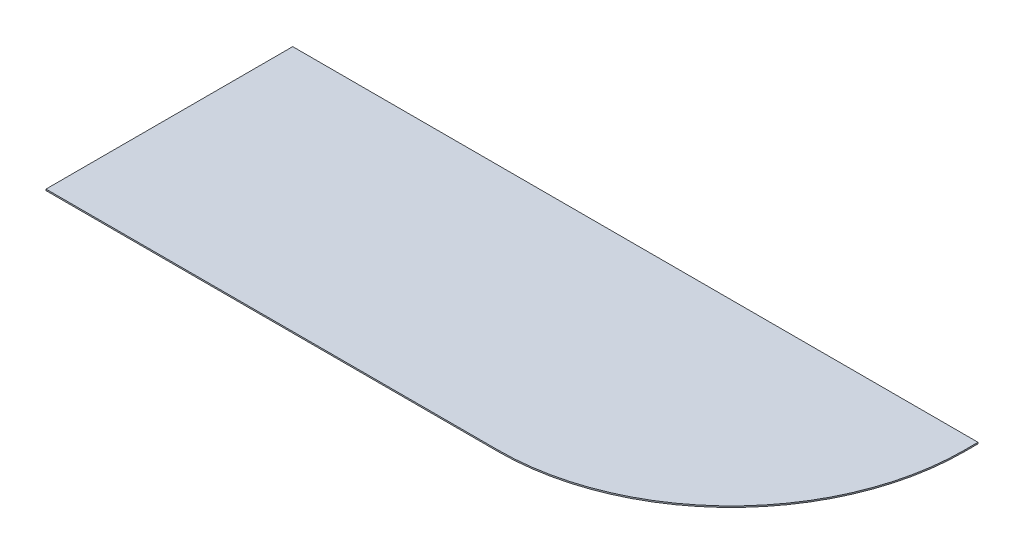
from build123d import *

# Parameters (mm, degrees)
WING_DEPTH = 1


with BuildPart() as part:
    # Sketch1 → wing (new body)
    with BuildSketch(Plane(origin=(0, 0, 0), x_dir=(1, 0, 0), z_dir=(0, 1, 0))):
        with BuildLine():
            Line((0, 0), (-500, 0))
            Line((-500, 0), (-500, -180))
            Line((-500, -180), (-170, -180))
            ThreePointArc((-170, -180), (-49.791847198, -130.208152802), (0, -10))
            Line((0, -10), (0, 0))
        make_face()
    extrude(amount=WING_DEPTH)


solid = part.part
